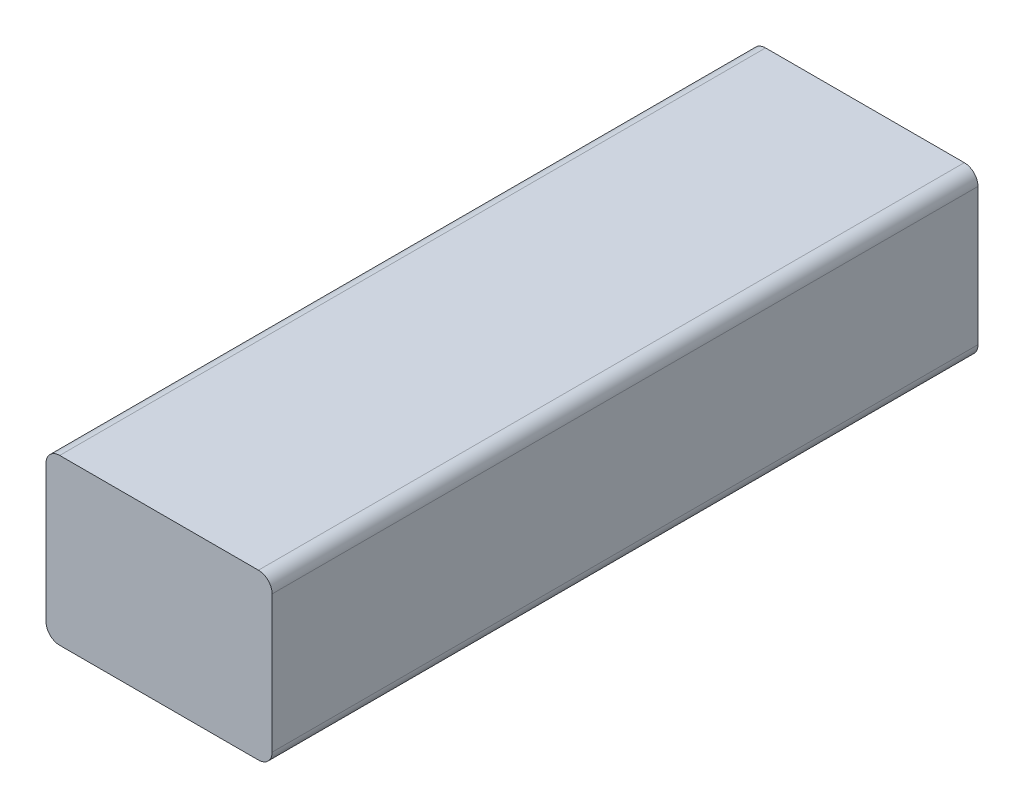
from build123d import *

# Parameters (mm, degrees)
SKETCH1_W           = 33
SKETCH1_H           = 103
BOSS_EXTRUDE1_DEPTH = 24
FILLET1_R           = 2


with BuildPart() as part:
    # Sketch1 → Boss-Extrude1 (new body)
    with BuildSketch(Plane(origin=(0, 0, 0), x_dir=(1, 0, 0), z_dir=(0, 1, 0))):
        Rectangle(SKETCH1_W, SKETCH1_H)
    extrude(amount=BOSS_EXTRUDE1_DEPTH)

    # Fillet1
    fillet1_edges = [part.edges().sort_by_distance(p)[0] for p in [
        (-16.5, 24, 0),
        (16.5, 24, 0),
        (-16.5, 0, 0),
        (16.5, 0, 0),
    ]]
    fillet(fillet1_edges, radius=FILLET1_R)


solid = part.part
